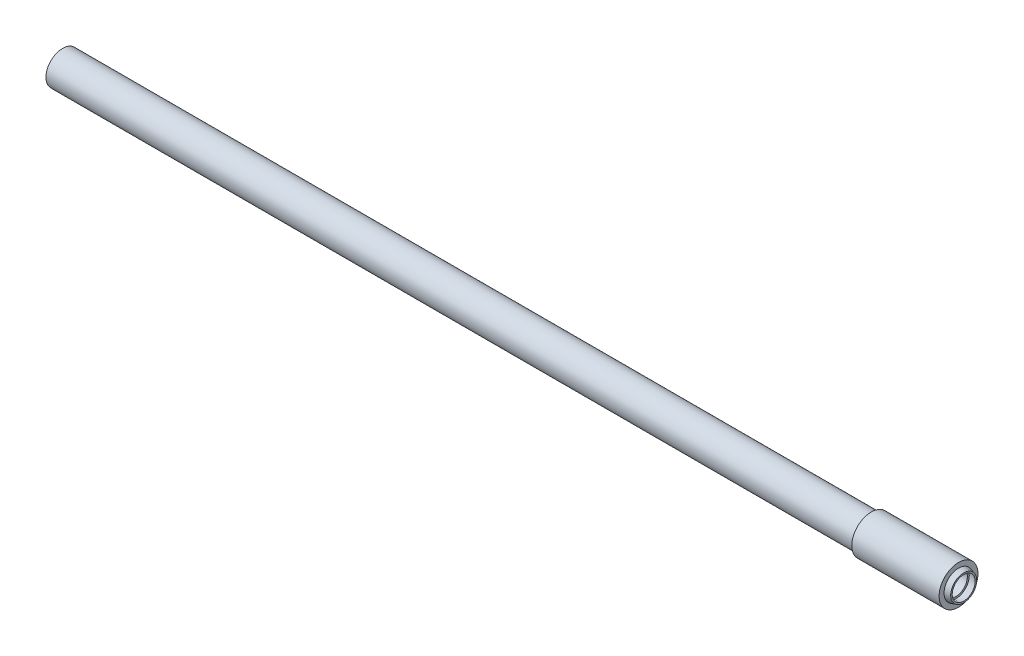
from build123d import *


with BuildPart() as part:
    # Sketch1 → Revolve1 (revolve)
    with BuildSketch(Plane(origin=(0, 0, 0), x_dir=(1, 0, 0), z_dir=(0, 1, 0))):
        Polygon((0, 4.9784), (-22.352, 4.9784), (-22.352, 4.2672), (-229.3112, 4.2672), (-229.3112, 2.9718), (-0.7112, 2.9718), (-0.7112, 3.4544), (1.3208, 2.9464), (1.3208, 3.3274), (0, 3.7084), align=None)
    revolve(axis=Axis((0, 0, 0), (-1, 0, 0)))


solid = part.part
